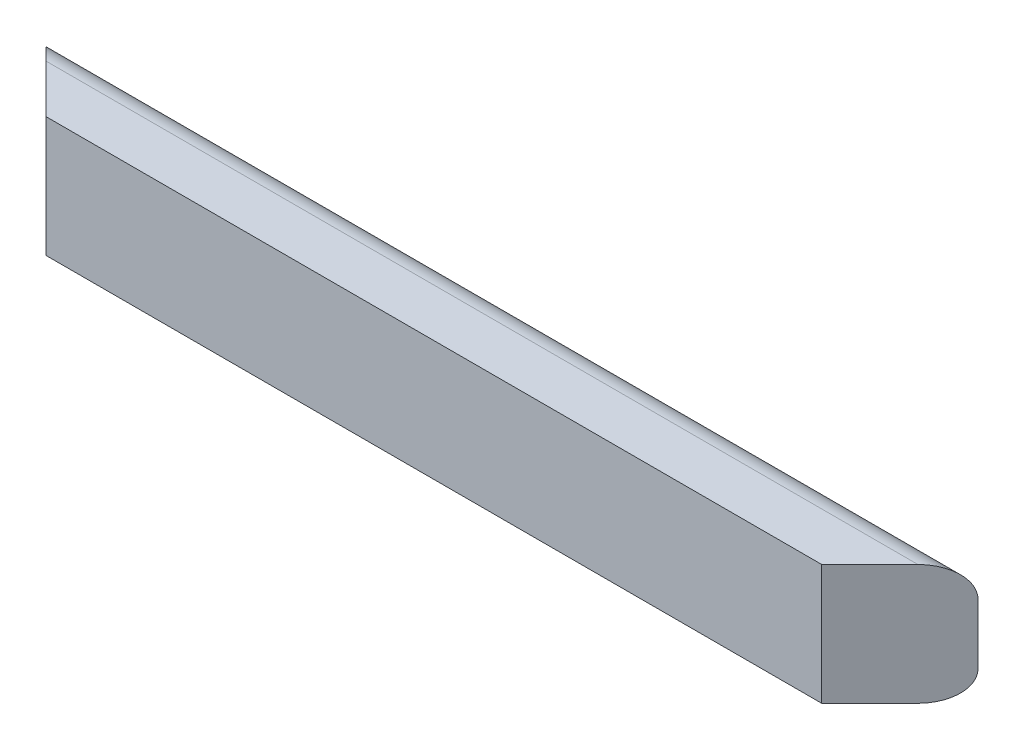
from build123d import *

# Parameters (mm, degrees)
BOSS_EXTRUDE1_DEPTH = 984.25
SKETCH2_W           = 344.402501539
SKETCH2_H           = 493.213131915
CUT_EXTRUDE1_DEPTH  = 59.371664787


with BuildPart() as part:
    # Sketch1 → Boss-Extrude1 (new body)
    with BuildSketch(Plane(origin=(0, 0, 0), x_dir=(0, 0, -1), z_dir=(1, 0, 0))):
        with BuildLine():
            Line((0, 0), (31.75, 0))
            ThreePointArc((31.75, 0), (54.200640303, 9.299359697), (63.5, 31.75))
            Line((63.5, 31.75), (63.5, 95.25))
            ThreePointArc((63.5, 95.25), (54.200640303, 117.700640303), (31.75, 127))
            Line((31.75, 127), (0, 127))
            Line((0, 127), (-19.05, 127))
            Line((-19.05, 127), (-19.05, 0))
            Line((-19.05, 0), (0, 0))
        make_face()
    extrude(amount=BOSS_EXTRUDE1_DEPTH)

    # Sketch2 → Cut-Extrude1 (cut, through all)
    with BuildSketch(Plane(origin=(460.375, 0, 460.375), x_dir=(0, 1, 0), z_dir=(0.707106781, 0, 0.707106781))):
        with Locations((32.995160032, -679.680893327)):
            Rectangle(SKETCH2_W, SKETCH2_H)
    cut_extrude1 = extrude(amount=CUT_EXTRUDE1_DEPTH, mode=Mode.SUBTRACT)

    # Mirror1: Cut-Extrude1 across plane
    add(cut_extrude1.mirror(Plane(origin=(492.125, 0, 0), x_dir=(0, 0, 1), z_dir=(1, 0, 0))), mode=Mode.SUBTRACT)


solid = part.part
